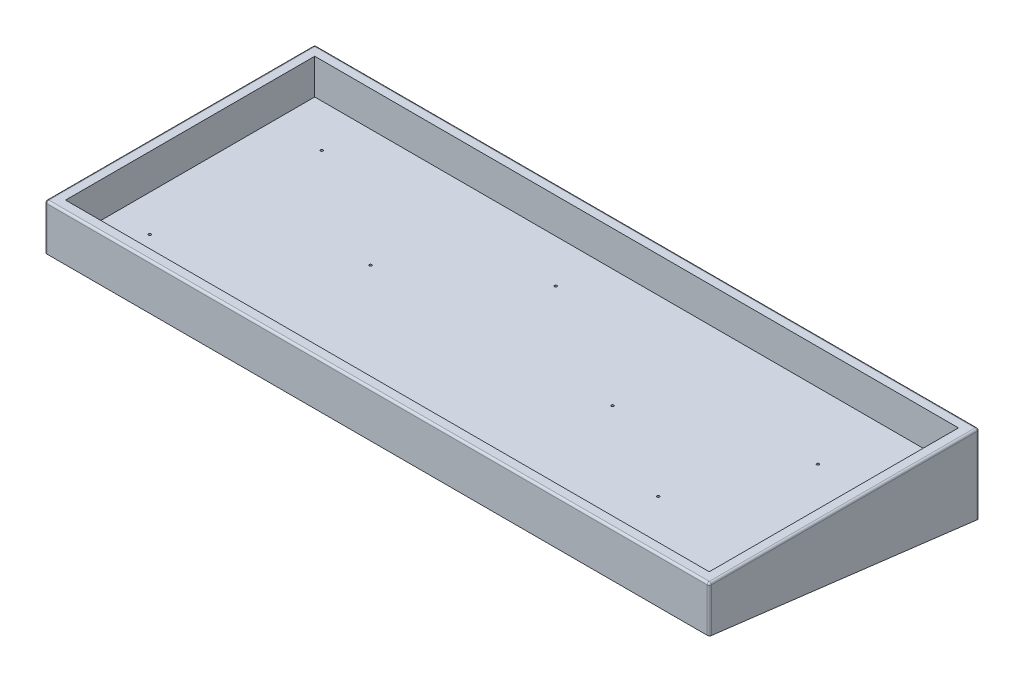
from build123d import *

# Parameters (mm, degrees)
SKETCH1_W             = 320
SKETCH1_H             = 130
BOSS_EXTRUDE3_DEPTH   = 22
SKETCH3_W             = 310
SKETCH3_H             = 120
CUT_EXTRUDE1_DEPTH    = 17
DRAFT1_ANGLE          = 7
FILLET2_R             = 1
F_0_80_TAPPED_HOLE1_D = 1.19126


with BuildPart() as part:
    # Sketch1 → Boss-Extrude3 (new body)
    with BuildSketch(Plane(origin=(0, 0, 0), x_dir=(1, 0, 0), z_dir=(0, 1, 0))):
        with Locations((160, 65)):
            Rectangle(SKETCH1_W, SKETCH1_H)
    extrude(amount=BOSS_EXTRUDE3_DEPTH)

    # Sketch3 → Cut-Extrude1 (cut)
    with BuildSketch(Plane(origin=(0, 22, 0), x_dir=(1, 0, 0), z_dir=(0, 1, 0))):
        with Locations((160, 65)):
            Rectangle(SKETCH3_W, SKETCH3_H)
    extrude(amount=-CUT_EXTRUDE1_DEPTH, mode=Mode.SUBTRACT)

    # Draft1
    draft1_faces = [part.faces().sort_by_distance(p)[0] for p in [
        (160, 0, -65),
    ]]
    draft(draft1_faces, Plane(origin=(0, 22, 0), x_dir=(1, 0, 0), z_dir=(0, 0, 1)), DRAFT1_ANGLE)

    # Fillet2
    fillet2_edges = [part.edges().sort_by_distance(p)[0] for p in [
        (320, 22, -65),
        (160, 22, -130),
        (0, 22, -65),
        (0, 3.019003541, -130),
        (320, 3.019003541, -130),
        (320, 11, 0),
        (0, 11, 0),
        (160, 22, 0),
    ]]
    fillet(fillet2_edges, radius=FILLET2_R)

    # #0-80 Tapped Hole1 (through all)
    with Locations(Plane(origin=(28.97111002, 5, -104.431910758), x_dir=(0, 0, 1), z_dir=(0, 1, 0))):
        with Locations((0, 0), (0.301233355, 112.962508169), (36.148002614, 59.644204314), (36.449235969, 176.522746099), (63.259004574, 225.322549628), (11.446867494, 250.324918103), (76.513272199, -6.325900457), (83.742872722, 139.169810064)):
            Hole(F_0_80_TAPPED_HOLE1_D / 2)


solid = part.part
